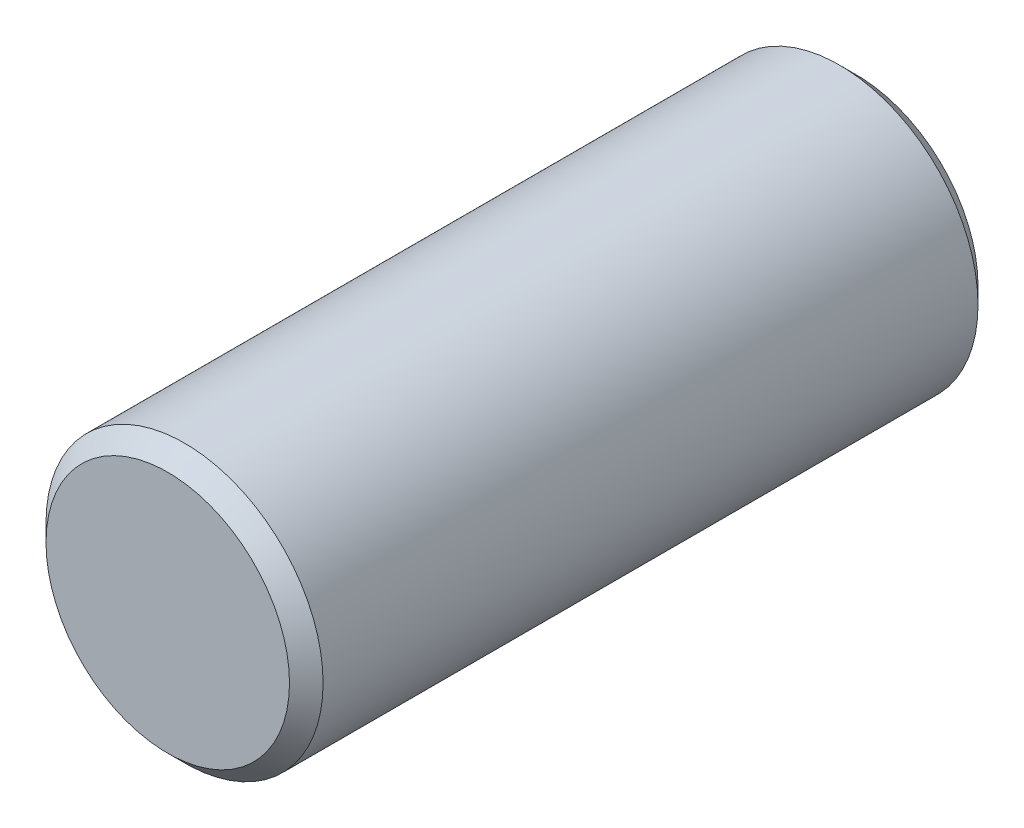
from build123d import *

# Parameters (mm, degrees)
SKETCH1_R           = 16.5
BOSS_EXTRUDE1_DEPTH = 41
CHAMFER1_SIZE       = 2


with BuildPart() as part:
    # Sketch1 → Boss-Extrude1 (new body, symmetric)
    with BuildSketch(Plane.XY):
        Circle(SKETCH1_R)
    extrude(amount=BOSS_EXTRUDE1_DEPTH, both=True)

    # Chamfer1
    chamfer1_edges = [part.edges().sort_by_distance(p)[0] for p in [
        (-16.5, 0, -41),
        (-16.5, 0, 41),
    ]]
    chamfer(chamfer1_edges, length=CHAMFER1_SIZE)


solid = part.part
